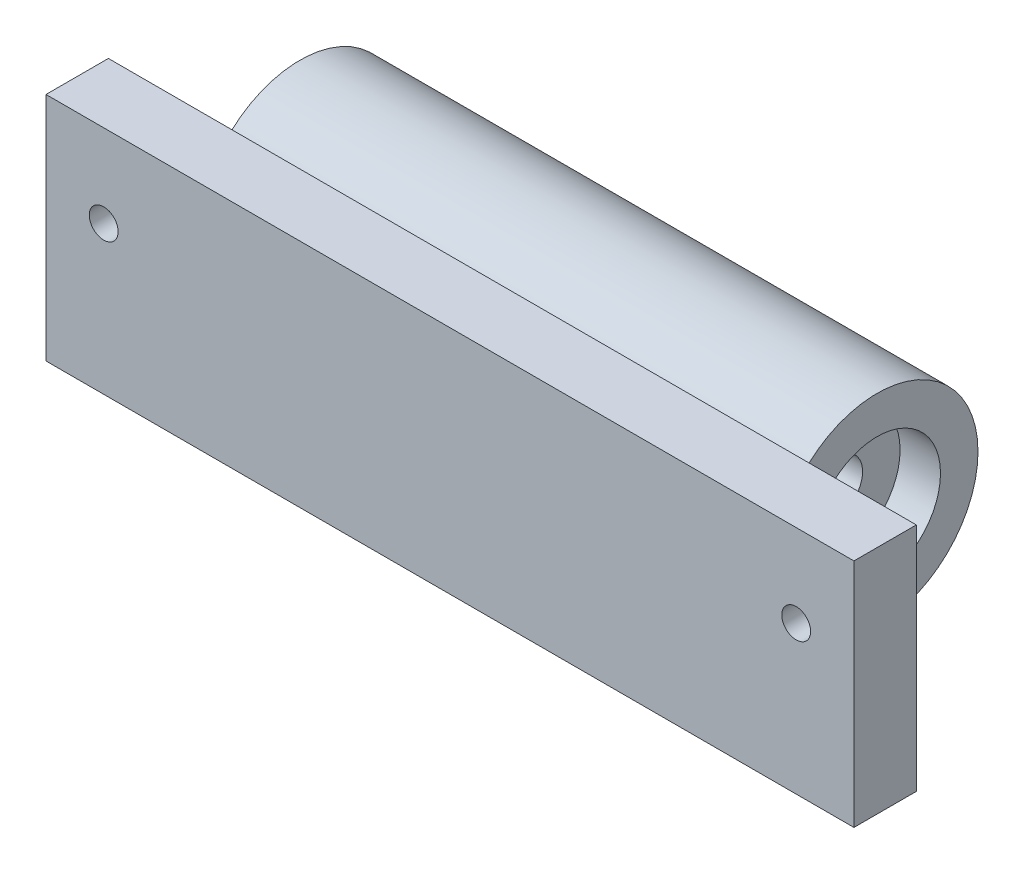
from build123d import *

# Parameters (mm, degrees)
SKETCH_1_R          = 4.5
EXTRUDE_1_DEPTH     = 100
SKETCH_2_W          = 10.811132722
SKETCH_2_H          = 40
EXTRUDE_2_DEPTH     = 20
SKETCH_3_W          = 10.811132722
SKETCH_3_H          = 40
EXTRUDE_3_DEPTH     = 20
SKETCH_4_R          = 2.5
CUT_EXTRUDE_1_DEPTH = 11.811132722
SKETCH_5_R          = 4.25
CUT_EXTRUDE_2_DEPTH = 5
SKETCH_6_R          = 11
CUT_EXTRUDE_3_DEPTH = 7
SKETCH_7_R          = 11
CUT_EXTRUDE_4_DEPTH = 7


with BuildPart() as part:
    # Эскиз1 → Бобышка-Вытянуть1 (new body)
    with BuildSketch(Plane(origin=(0, 0, 0), x_dir=(0, 0, -1), z_dir=(1, 0, 0))):
        with BuildLine():
            Line((-24, 14.353267579), (-13.188867278, 14.353267579))
            Line((-13.188867278, 14.353267579), (-13.188867278, 11.502338019))
            ThreePointArc((-13.188867278, 11.502338019), (17.5, 0), (-13.188867278, -11.502338019))
            Line((-13.188867278, -11.502338019), (-13.188867278, -25.646732421))
            Line((-13.188867278, -25.646732421), (-24, -25.646732421))
            Line((-24, -25.646732421), (-24, 14.353267579))
        make_face()
        Circle(SKETCH_1_R, mode=Mode.SUBTRACT)
    extrude(amount=EXTRUDE_1_DEPTH)

    # Эскиз2 → Бобышка-Вытянуть2 (add)
    with BuildSketch(Plane.ZY):
        with Locations((18.594433639, -5.646732421)):
            Rectangle(SKETCH_2_W, SKETCH_2_H)
    extrude(amount=EXTRUDE_2_DEPTH)

    # Эскиз3 → Бобышка-Вытянуть3 (add)
    with BuildSketch(Plane(origin=(100, 0, 0), x_dir=(0, 0, -1), z_dir=(1, 0, 0))):
        with Locations((-18.594433639, -5.646732421)):
            Rectangle(SKETCH_3_W, SKETCH_3_H)
    extrude(amount=EXTRUDE_3_DEPTH)

    # Эскиз4 → Вырез-Вытянуть1 (cut, through all)
    with BuildSketch(Plane(origin=(0, 0, 13.188867278), x_dir=(-1, 0, 0), z_dir=(0, 0, -1))):
        with Locations((-110, 0)):
            Circle(SKETCH_4_R)
        with Locations((10, 0)):
            Circle(SKETCH_4_R)
    extrude(amount=-CUT_EXTRUDE_1_DEPTH, mode=Mode.SUBTRACT)

    # Эскиз5 → Вырез-Вытянуть2 (cut)
    with BuildSketch(Plane(origin=(0, 0, 13.188867278), x_dir=(-1, 0, 0), z_dir=(0, 0, -1))):
        with Locations((-110, 0)):
            Circle(SKETCH_5_R)
        with Locations((10, 0)):
            Circle(SKETCH_5_R)
    extrude(amount=-CUT_EXTRUDE_2_DEPTH, mode=Mode.SUBTRACT)

    # Эскиз6 → Вырез-Вытянуть3 (cut)
    with BuildSketch(Plane(origin=(100, 0, 0), x_dir=(0, 0, -1), z_dir=(1, 0, 0))):
        Circle(SKETCH_6_R)
    extrude(amount=-CUT_EXTRUDE_3_DEPTH, mode=Mode.SUBTRACT)

    # Эскиз7 → Вырез-Вытянуть4 (cut)
    with BuildSketch(Plane.ZY):
        Circle(SKETCH_7_R)
    extrude(amount=-CUT_EXTRUDE_4_DEPTH, mode=Mode.SUBTRACT)


solid = part.part
